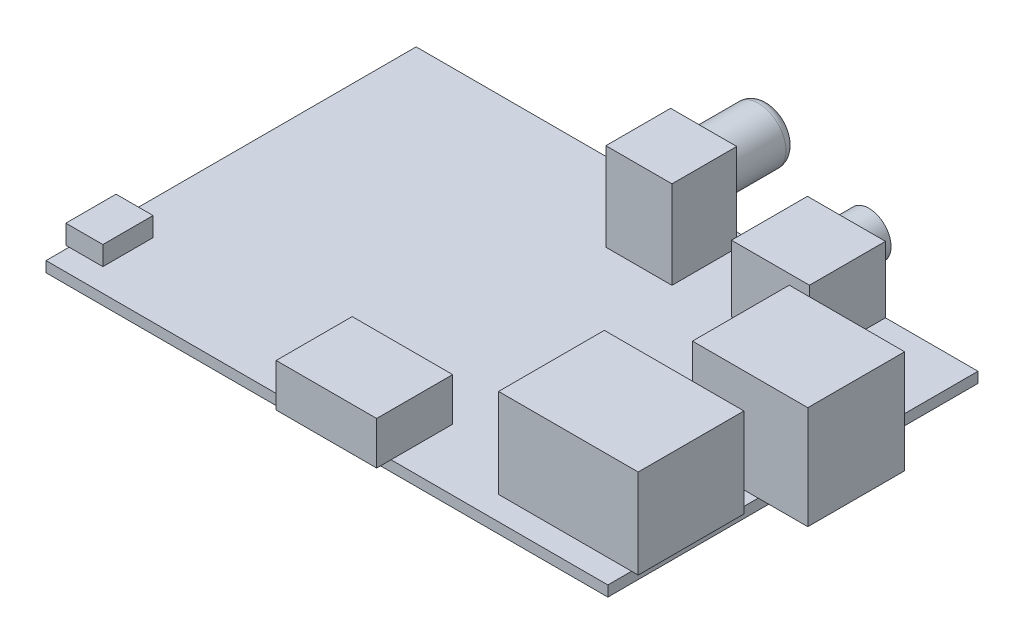
from build123d import *

# Parameters (mm, degrees)
SKETCH1_W            = 85
SKETCH1_H            = 56
BOSS_EXTRUDE1_DEPTH  = 1.6
SKETCH5_W            = 5.6
SKETCH5_H            = 7.6
BOSS_EXTRUDE4_DEPTH  = 2.9
SKETCH7_W            = 15.2
SKETCH7_H            = 11.5
BOSS_EXTRUDE5_DEPTH  = 6.5
SKETCH8_W            = 21.12
SKETCH8_H            = 16
BOSS_EXTRUDE6_DEPTH  = 13.5
SKETCH9_W            = 17.45
SKETCH9_H            = 14.65
BOSS_EXTRUDE7_DEPTH  = 15.6
SKETCH10_W           = 11.8
SKETCH10_H           = 11.5
BOSS_EXTRUDE8_DEPTH  = 10.02
SKETCH11_R           = 3.35
BOSS_EXTRUDE9_DEPTH  = 3.4
SKETCH12_W           = 10
SKETCH12_H           = 9.8
BOSS_EXTRUDE10_DEPTH = 13.3
SKETCH14_R           = 4.15
BOSS_EXTRUDE11_DEPTH = 9.8
SKETCH15_W           = 19
SKETCH15_H           = 30
BOSS_EXTRUDE12_DEPTH = 5
SKETCH16_R           = 2.25
CUT_EXTRUDE1_DEPTH   = 8
FILLET1_R            = 1.5
SKETCH17_R           = 1.775
CUT_EXTRUDE2_DEPTH   = 8
FILLET2_R            = 0.25


with BuildPart() as part:
    # Sketch1 → Boss-Extrude1 (new body)
    with BuildSketch(Plane(origin=(0, 0, 0), x_dir=(1, 0, 0), z_dir=(0, 1, 0))):
        Rectangle(SKETCH1_W, SKETCH1_H)
    extrude(amount=BOSS_EXTRUDE1_DEPTH)

    # Sketch5 → Boss-Extrude4 (add)
    with BuildSketch(Plane(origin=(0, 1.6, 0), x_dir=(1, 0, 0), z_dir=(0, 1, 0))):
        with Locations((-40.2, -20.7)):
            Rectangle(SKETCH5_W, SKETCH5_H)
    extrude(amount=BOSS_EXTRUDE4_DEPTH)

    # Sketch7 → Boss-Extrude5 (add)
    with BuildSketch(Plane(origin=(0, 1.6, 0), x_dir=(1, 0, 0), z_dir=(0, 1, 0))):
        with Locations((2.1, -24.428660954)):
            Rectangle(SKETCH7_W, SKETCH7_H)
    extrude(amount=BOSS_EXTRUDE5_DEPTH)

    # Sketch8 → Boss-Extrude6 (add)
    with BuildSketch(Plane(origin=(0, 1.6, 0), x_dir=(1, 0, 0), z_dir=(0, 1, 0))):
        with Locations((32.94, -16.409823937)):
            Rectangle(SKETCH8_W, SKETCH8_H)
    extrude(amount=BOSS_EXTRUDE6_DEPTH)

    # Sketch9 → Boss-Extrude7 (add)
    with BuildSketch(Plane(origin=(0, 1.6, 0), x_dir=(1, 0, 0), z_dir=(0, 1, 0))):
        with Locations((41.275, 2.075)):
            Rectangle(SKETCH9_W, SKETCH9_H)
    extrude(amount=BOSS_EXTRUDE7_DEPTH)

    # Sketch10 → Boss-Extrude8 (add)
    with BuildSketch(Plane(origin=(0, 1.6, 0), x_dir=(1, 0, 0), z_dir=(0, 1, 0))):
        with Locations((22.6, 22.25)):
            Rectangle(SKETCH10_W, SKETCH10_H)
    extrude(amount=BOSS_EXTRUDE8_DEPTH)

    # Sketch11 → Boss-Extrude9 (add)
    with BuildSketch(Plane(origin=(0, 0, -28), x_dir=(-1, 0, 0), z_dir=(0, 0, -1))):
        with Locations((-22.6, 7.95)):
            Circle(SKETCH11_R)
    extrude(amount=BOSS_EXTRUDE9_DEPTH)

    # Sketch12 → Boss-Extrude10 (add)
    with BuildSketch(Plane(origin=(0, 1.6, 0), x_dir=(1, 0, 0), z_dir=(0, 1, 0))):
        with Locations((3.1, 21)):
            Rectangle(SKETCH12_W, SKETCH12_H)
    extrude(amount=BOSS_EXTRUDE10_DEPTH)

    # Sketch14 → Boss-Extrude11 (add)
    with BuildSketch(Plane(origin=(0, 0, -25.9), x_dir=(-1, 0, 0), z_dir=(0, 0, -1))):
        with Locations((-3.1, 9.75)):
            Circle(SKETCH14_R)
    extrude(amount=BOSS_EXTRUDE11_DEPTH)

    # Sketch15 → Boss-Extrude12 (add)
    with BuildSketch(Plane.XZ):
        with Locations((-32, -1.5)):
            Rectangle(SKETCH15_W, SKETCH15_H)
    extrude(amount=BOSS_EXTRUDE12_DEPTH)

    # Sketch16 → Cut-Extrude1 (cut)
    with BuildSketch(Plane(origin=(0, 0, -35.7), x_dir=(-1, 0, 0), z_dir=(0, 0, -1))):
        with Locations((-3.1, 9.75)):
            Circle(SKETCH16_R)
    extrude(amount=-CUT_EXTRUDE1_DEPTH, mode=Mode.SUBTRACT)

    # Fillet1
    fillet1_edges = [part.edges().sort_by_distance(p)[0] for p in [
        (7.25, 9.75, -35.7),
    ]]
    fillet(fillet1_edges, radius=FILLET1_R)

    # Sketch17 → Cut-Extrude2 (cut)
    with BuildSketch(Plane(origin=(0, 0, -31.4), x_dir=(-1, 0, 0), z_dir=(0, 0, -1))):
        with Locations((-22.6, 7.95)):
            Circle(SKETCH17_R)
    extrude(amount=-CUT_EXTRUDE2_DEPTH, mode=Mode.SUBTRACT)

    # Fillet2
    fillet2_edges = [part.edges().sort_by_distance(p)[0] for p in [
        (24.375, 7.95, -31.4),
    ]]
    fillet(fillet2_edges, radius=FILLET2_R)


solid = part.part
